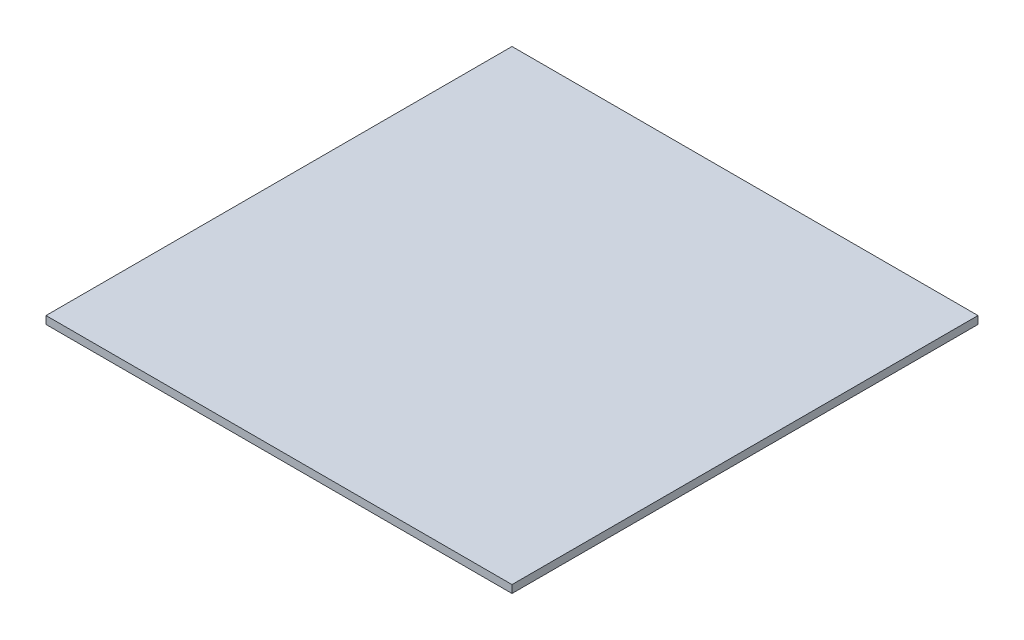
from build123d import *

# Parameters (mm, degrees)
SKETCH1_W           = 190.5
SKETCH1_H           = 190.5
BOSS_EXTRUDE1_DEPTH = 3.175


with BuildPart() as part:
    # Sketch1 → Boss-Extrude1 (new body)
    with BuildSketch(Plane(origin=(0, 0, 0), x_dir=(1, 0, 0), z_dir=(0, 1, 0))):
        Rectangle(SKETCH1_W, SKETCH1_H)
    extrude(amount=BOSS_EXTRUDE1_DEPTH)


solid = part.part
